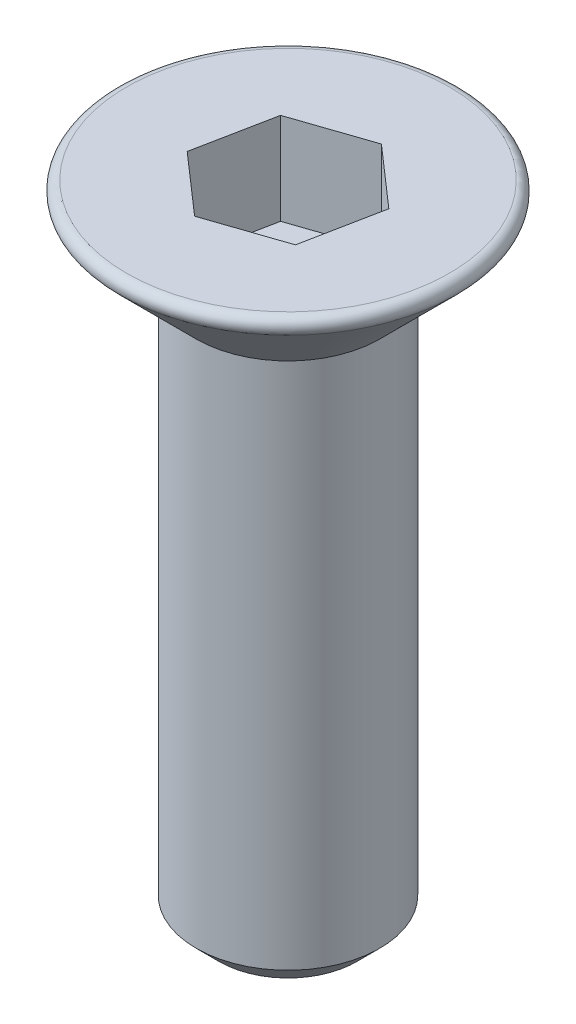
from build123d import *

# Parameters (mm, degrees)
SKETCH1_R           = 2
BOSS_EXTRUDE3_DEPTH = 12
CHAMFER2_SIZE       = 0.5
CUT_EXTRUDE1_DEPTH  = 2


with BuildPart() as part:
    # Sketch1 → Boss-Extrude3 (new body)
    with BuildSketch(Plane(origin=(0, 0, 0), x_dir=(1, 0, 0), z_dir=(0, 1, 0))):
        Circle(SKETCH1_R)
    extrude(amount=-BOSS_EXTRUDE3_DEPTH)

    # Sketch3 → Revolve2 (revolve)
    with BuildSketch(Plane.XY):
        with BuildLine():
            Line((-2, 0), (0, 0))
            Line((0, 0), (0, 2))
            Line((0, 2), (-3.517157288, 2))
            ThreePointArc((-3.517157288, 2), (-3.701933194, 1.876536686), (-3.658578644, 1.658578644))
            Line((-3.658578644, 1.658578644), (-2, 0))
        make_face()
    revolve(axis=Axis((0, -2, 0), (0, 1, 0)))

    # Chamfer2
    chamfer2_edges = [part.edges().sort_by_distance(p)[0] for p in [
        (-2, -12, 0),
    ]]
    chamfer(chamfer2_edges, length=CHAMFER2_SIZE)

    # Sketch4 → Cut-Extrude1 (cut)
    with BuildSketch(Plane(origin=(0, 2, 0), x_dir=(1, 0, 0), z_dir=(0, 1, 0))):
        Polygon((1.303085549, -1.141038146), (1.639710796, 0.557986116), (0.336625247, 1.699024262), (-1.303085549, 1.141038146), (-1.639710796, -0.557986116), (-0.336625247, -1.699024262), align=None)
    extrude(amount=-CUT_EXTRUDE1_DEPTH, mode=Mode.SUBTRACT)


solid = part.part
